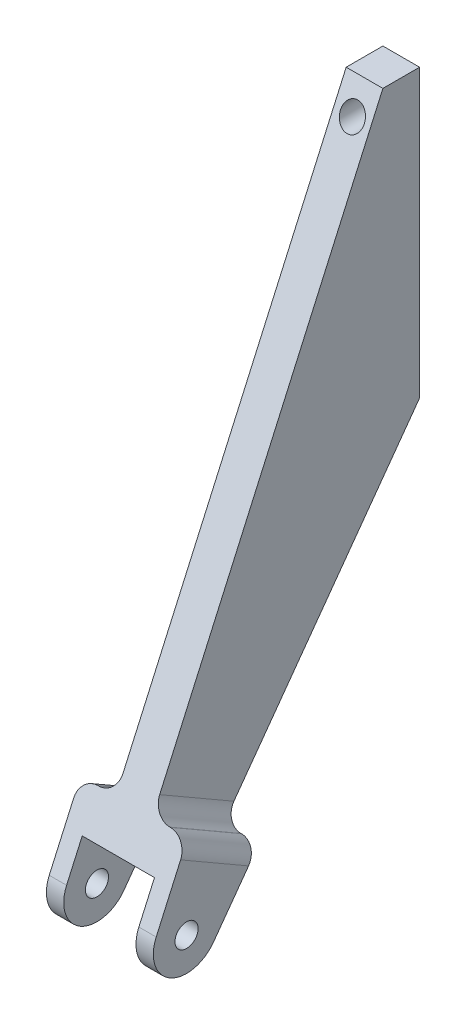
from build123d import *

# Parameters (mm, degrees)
SKETCH1_W           = 12.7
SKETCH1_H           = 319.323239592
BOSS_EXTRUDE1_DEPTH = 112.776
SKETCH2_R           = 4
CUT_EXTRUDE1_DEPTH  = 13.7
SKETCH3_R           = 4.1275
CUT_EXTRUDE2_DEPTH  = 25.4
SKETCH4_R           = 4
BOSS_EXTRUDE2_DEPTH = 18.5
CUT_EXTRUDE3_DEPTH  = 12.5
FILLET1_R           = 6


with BuildPart() as part:
    # Sketch1 → Boss-Extrude1 (new body)
    with BuildSketch(Plane.XY):
        with Locations((-72.058445247, -162.550776628)):
            Rectangle(SKETCH1_W, SKETCH1_H)
    extrude(amount=BOSS_EXTRUDE1_DEPTH)

    # Sketch2 → Cut-Extrude1 (cut, through all)
    with BuildSketch(Plane(origin=(-65.708445247, 0, 0), x_dir=(0, 0, -1), z_dir=(1, 0, 0))):
        with BuildLine():
            Line((0, -322.212396424), (0, -102))
            Line((0, -102), (-83.459642539, -217.229583096))
            ThreePointArc((-83.459642539, -217.229583096), (-98.52075591, -220.444553487), (-103.27456158, -205.796191727))
            Line((-103.27456158, -205.796191727), (-12.7, -2.889156832))
            Line((-12.7, -2.889156832), (-112.776, -2.889156832))
            Line((-112.776, -2.889156832), (-112.776, -322.212396424))
            Line((-112.776, -322.212396424), (0, -322.212396424))
        make_face()
        with Locations((-92.773303784, -210.483790762)):
            Circle(SKETCH2_R)
    extrude(amount=-CUT_EXTRUDE1_DEPTH, mode=Mode.SUBTRACT)

    # Sketch3 → Cut-Extrude2 (cut)
    with BuildSketch(Plane(origin=(0, 0, 0), x_dir=(-1, 0, 0), z_dir=(0, 0, -1))):
        with Locations((72, -12.414156832)):
            Circle(SKETCH3_R)
        with Locations((72, -91.789156832)):
            Circle(SKETCH3_R)
    extrude(amount=-CUT_EXTRUDE2_DEPTH, mode=Mode.SUBTRACT)

    # Sketch4 → Boss-Extrude2 (add, symmetric)
    with BuildSketch(Plane(origin=(-72.058445247, 0, 0), x_dir=(0, 0, -1), z_dir=(1, 0, 0))):
        with BuildLine():
            Line((-67.779388484, -195.580447266), (-92.378474043, -181.386547612))
            Line((-92.378474043, -181.386547612), (-103.27456158, -205.796191727))
            ThreePointArc((-103.27456158, -205.796191727), (-98.52075591, -220.444553487), (-83.459642539, -217.229583096))
            Line((-83.459642539, -217.229583096), (-67.779388484, -195.580447266))
        make_face()
        with Locations((-92.773303784, -210.483790762)):
            Circle(SKETCH4_R, mode=Mode.SUBTRACT)
    extrude(amount=BOSS_EXTRUDE2_DEPTH, both=True)

    # Sketch6 → Cut-Extrude3 (cut, symmetric)
    with BuildSketch(Plane(origin=(-72.058445247, 0, 0), x_dir=(0, 0, -1), z_dir=(1, 0, 0))):
        Polygon((-102.882650108, -190.796243791), (-56.569606998, -217.519297579), (-85.086213735, -269.679128088), (-153.833763242, -230.32789021), align=None)
    extrude(amount=CUT_EXTRUDE3_DEPTH, both=True, mode=Mode.SUBTRACT)

    # Fillet1
    fillet1_edges = [part.edges().sort_by_distance(p)[0] for p in [
        (-65.708445247, -188.483497439, 80.078931263),
        (-78.408445247, -188.483497439, 80.078931263),
        (-90.558445247, -188.483497439, 80.078931263),
        (-53.558445247, -188.483497439, 80.078931263),
    ]]
    fillet(fillet1_edges, radius=FILLET1_R)


solid = part.part
